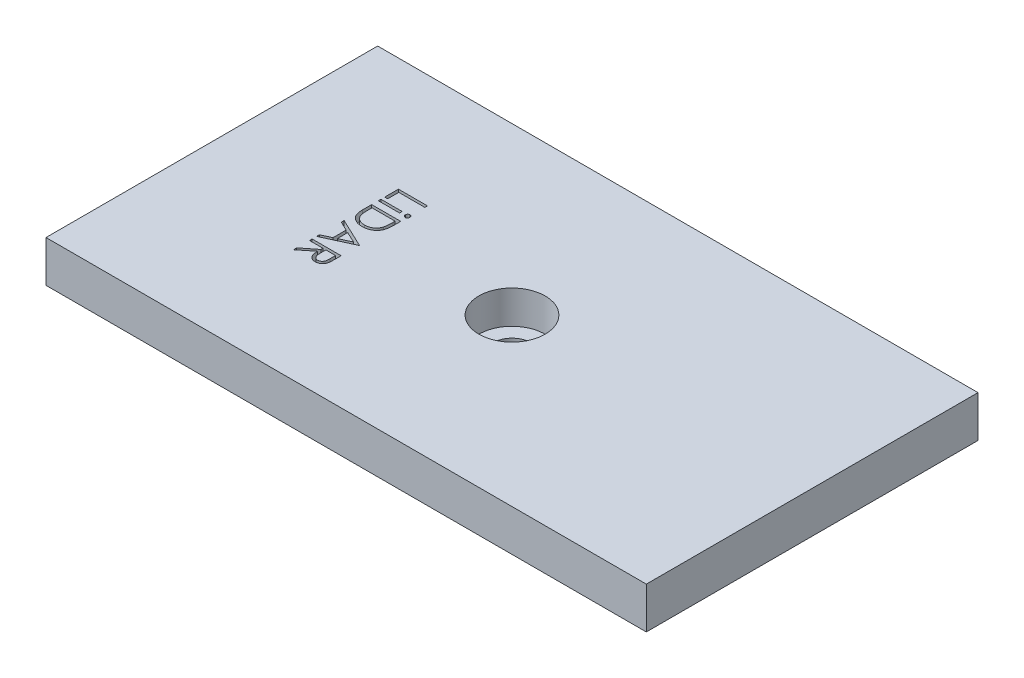
from build123d import *

# Parameters (mm, degrees)
SKETCH1_W                      = 72.4
SKETCH1_H                      = 40
BOSS_EXTRUDE1_DEPTH            = 6
CHAMFER1_SIZE                  = 1
CBORE_FOR_M4_SHCS1_D           = 4.5
CBORE_FOR_M4_SHCS1_DEPTH       = 6
CBORE_FOR_M4_SHCS1_CBORE_D     = 8
CBORE_FOR_M4_SHCS1_CBORE_DEPTH = 4
SKETCH4_W                      = 2.557692308
SKETCH4_H                      = 0.314102565
CUT_EXTRUDE1_DEPTH             = 1


with BuildPart() as part:
    # Sketch1 → Boss-Extrude1 (new body)
    with BuildSketch(Plane(origin=(0, 0, 0), x_dir=(1, 0, 0), z_dir=(0, 1, 0))):
        Rectangle(SKETCH1_W, SKETCH1_H)
    extrude(amount=BOSS_EXTRUDE1_DEPTH)

    # Chamfer1
    chamfer1_edges = [part.edges().sort_by_distance(p)[0] for p in [
        (0, 0, 20),
        (-36.2, 0, 0),
        (0, 0, -20),
        (36.2, 0, 0),
    ]]
    chamfer(chamfer1_edges, length=CHAMFER1_SIZE)

    # CBORE for M4 SHCS1
    with Locations(Plane(origin=(0, 6, 0), x_dir=(1, 0, 0), z_dir=(0, 1, 0))):
        with Locations((0, 0)):
            CounterBoreHole(CBORE_FOR_M4_SHCS1_D / 2, CBORE_FOR_M4_SHCS1_CBORE_D / 2, CBORE_FOR_M4_SHCS1_CBORE_DEPTH, depth=CBORE_FOR_M4_SHCS1_DEPTH)

    # Sketch4 → Cut-Extrude1 (cut)
    with BuildSketch(Plane(origin=(0, 6, 0), x_dir=(1, 0, 0), z_dir=(0, 1, 0))):
        Polygon((-16.5, 6.304487179), (-16.5, 5.990384615), (-19.641025641, 5.990384615), (-19.641025641, 4.644230769), (-20, 4.644230769), (-20, 6.304487179), align=None)
        with BuildLine():
            add(Edge.make_bspline(
                [(-16.365384615, 4.039863782), (-16.36629269, 4.020375721), (-16.368070874, 3.982214354), (-16.383176643, 3.92697486), (-16.409172417, 3.876726064), (-16.442915564, 3.831491473), (-16.484230683, 3.793994076), (-16.53117379, 3.767106447), (-16.58227867, 3.749941466), (-16.617887461, 3.747856453), (-16.636017628, 3.746794872)],
                knots=[0, 0, 0, 0, 5.84e-05, 0.000114358, 0.000170171, 0.000227242, 0.000282848, 0.000336244, 0.00038857, 0.000442847, 0.000442847, 0.000442847, 0.000442847], degree=3))
            add(Edge.make_bspline(
                [(-16.636017628, 3.746794872), (-16.653677192, 3.747880202), (-16.688588061, 3.75002577), (-16.738806847, 3.767093758), (-16.785096281, 3.794219497), (-16.826330626, 3.831466515), (-16.86005428, 3.876732655), (-16.886055203, 3.926973116), (-16.901159612, 3.982214812), (-16.902937984, 4.020375876), (-16.903846154, 4.039863782)],
                knots=[0, 0, 0, 0, 5.2882e-05, 0.000104542, 0.000157332, 0.000212937, 0.000270009, 0.000325822, 0.00038178, 0.00044018, 0.00044018, 0.00044018, 0.00044018], degree=3))
            add(Edge.make_bspline(
                [(-16.903846154, 4.039863782), (-16.902967151, 4.059127865), (-16.901256287, 4.096622886), (-16.885874492, 4.150846688), (-16.860110821, 4.200286964), (-16.825863936, 4.2447818), (-16.785370463, 4.282767293), (-16.738771881, 4.309792946), (-16.688596963, 4.326906568), (-16.653680183, 4.329045986), (-16.636017628, 4.330128205)],
                knots=[0, 0, 0, 0, 5.7701e-05, 0.000112308, 0.000167496, 0.000224009, 0.000280086, 0.000332875, 0.000384535, 0.000437418, 0.000437418, 0.000437418, 0.000437418], degree=3))
            add(Edge.make_bspline(
                [(-16.636017628, 4.330128205), (-16.617884357, 4.32906985), (-16.582269469, 4.326991175), (-16.531209353, 4.309779663), (-16.483954162, 4.282995494), (-16.443381916, 4.244757256), (-16.409116, 4.200293389), (-16.383357305, 4.150845015), (-16.36797421, 4.096623331), (-16.366263526, 4.059128016), (-16.365384615, 4.039863782)],
                knots=[0, 0, 0, 0, 5.4277e-05, 0.000106603, 0.000159999, 0.000216076, 0.000272589, 0.000327778, 0.000382384, 0.000440085, 0.000440085, 0.000440085, 0.000440085], degree=3))
        make_face()
        with Locations((-18.721153846, 4.038461539)):
            Rectangle(SKETCH4_W, SKETCH4_H)
        with BuildLine():
            Line((-20, 3.073717949), (-16.5, 3.073717949))
            Line((-16.5, 3.073717949), (-16.5, 2.366987179))
            add(Edge.make_bspline(
                [(-16.5, 2.366987179), (-16.500441364, 2.305518063), (-16.501294077, 2.186760051), (-16.506731622, 2.015149315), (-16.516253523, 1.856592024), (-16.530390835, 1.711178219), (-16.547359571, 1.578674282), (-16.568939567, 1.459292433), (-16.594319104, 1.352839205), (-16.615965573, 1.287369893), (-16.626201923, 1.256410256)],
                knots=[0, 0, 0, 0, 0.000184407, 0.000356273, 0.000515031, 0.000660839, 0.000794505, 0.000915661, 0.001024663, 0.001122451, 0.001122451, 0.001122451, 0.001122451], degree=3))
            add(Edge.make_bspline(
                [(-16.626201923, 1.256410256), (-16.641632646, 1.215915543), (-16.672144174, 1.135844401), (-16.729700224, 1.021836906), (-16.794914263, 0.914512932), (-16.867866673, 0.813288668), (-16.950643905, 0.720506945), (-17.039652514, 0.632427168), (-17.138529639, 0.553003306), (-17.243918105, 0.479048035), (-17.356887031, 0.414335964), (-17.475143662, 0.357267433), (-17.598466726, 0.308540873), (-17.727753834, 0.270520736), (-17.861763837, 0.239109628), (-18.001511188, 0.218033522), (-18.146181197, 0.204033518), (-18.244356924, 0.202633458), (-18.294170673, 0.201923077)],
                knots=[0, 0, 0, 0, 0.000129935, 0.000256923, 0.000382457, 0.000506429, 0.000630624, 0.000755071, 0.000881654, 0.001010603, 0.001140963, 0.001271727, 0.001404269, 0.001538244, 0.001675666, 0.001816872, 0.001961916, 0.002111314, 0.002111314, 0.002111314, 0.002111314], degree=3))
            add(Edge.make_bspline(
                [(-18.294170673, 0.201923077), (-18.337431765, 0.202552468), (-18.422682266, 0.20379275), (-18.548325256, 0.214915999), (-18.670231175, 0.231114488), (-18.787864626, 0.256078288), (-18.902018041, 0.286752778), (-19.012149321, 0.324614557), (-19.118339189, 0.369484432), (-19.219722654, 0.421542498), (-19.316131997, 0.478465682), (-19.405908182, 0.540878622), (-19.490758634, 0.605199855), (-19.566856155, 0.676388957), (-19.638553014, 0.749540211), (-19.701975299, 0.828532684), (-19.759885634, 0.910792849), (-19.811861317, 0.997905167), (-19.856955979, 1.091957586), (-19.895587774, 1.194233797), (-19.927397179, 1.305281562), (-19.95397895, 1.424930671), (-19.975053061, 1.553415572), (-19.989180388, 1.690854121), (-19.998733053, 1.83703753), (-19.999569484, 1.937416778), (-20, 1.989082532)],
                knots=[0, 0, 0, 0, 0.000129755, 0.000255696, 0.000378151, 0.000498469, 0.000616165, 0.000732571, 0.000847557, 0.000961693, 0.00107424, 0.001183147, 0.00128959, 0.001393302, 0.001495449, 0.001596627, 0.001696799, 0.001797082, 0.001900566, 0.002009296, 0.002124673, 0.002246805, 0.002376823, 0.002515029, 0.002661147, 0.00281612, 0.00281612, 0.00281612, 0.00281612], degree=3))
            Line((-20, 1.989082532), (-20, 3.073717949))
        make_face()
        with BuildLine():
            Line((-19.641025641, 2.759615385), (-19.641025641, 2.357872596))
            add(Edge.make_bspline(
                [(-19.641025641, 2.357872596), (-19.640777545, 2.300144225), (-19.640300364, 2.189111427), (-19.636113161, 2.02945343), (-19.629271224, 1.883574033), (-19.619696146, 1.751452524), (-19.607027531, 1.6331635), (-19.592902628, 1.52845975), (-19.575305177, 1.437684491), (-19.559354218, 1.382755054), (-19.551983173, 1.357371795)],
                knots=[0, 0, 0, 0, 0.000173183, 0.000333094, 0.000479096, 0.000611272, 0.000730431, 0.000835931, 0.000928194, 0.001007458, 0.001007458, 0.001007458, 0.001007458], degree=3))
            add(Edge.make_bspline(
                [(-19.551983173, 1.357371795), (-19.540732453, 1.325422757), (-19.518499737, 1.262287784), (-19.477929951, 1.171416467), (-19.429932617, 1.086623422), (-19.376265429, 1.006494005), (-19.316097236, 0.931547084), (-19.249245929, 0.86211514), (-19.176450828, 0.797704694), (-19.09743924, 0.739020336), (-19.012721991, 0.68658277), (-18.923377605, 0.640877622), (-18.829621713, 0.602097478), (-18.731116394, 0.570563618), (-18.627954501, 0.546126688), (-18.52040743, 0.528740101), (-18.40844163, 0.517931407), (-18.332289855, 0.516669123), (-18.293469551, 0.516025641)],
                knots=[0, 0, 0, 0, 0.000101593, 0.000200759, 0.000298073, 0.000393552, 0.0004898, 0.000585999, 0.000682362, 0.000781081, 0.000880892, 0.000980919, 0.001081827, 0.00118493, 0.001290876, 0.00139957, 0.001511544, 0.001627983, 0.001627983, 0.001627983, 0.001627983], degree=3))
            add(Edge.make_bspline(
                [(-18.293469551, 0.516025641), (-18.252536316, 0.516539475), (-18.172122613, 0.517548908), (-18.054128443, 0.530215463), (-17.940660382, 0.548765119), (-17.831636737, 0.575447354), (-17.72719935, 0.6099185), (-17.626758196, 0.65116602), (-17.531605855, 0.701246984), (-17.440936425, 0.757943931), (-17.356123035, 0.821596637), (-17.278159321, 0.891922741), (-17.206900054, 0.968180698), (-17.142231778, 1.050019059), (-17.08530453, 1.138582062), (-17.034662938, 1.232371046), (-16.99163483, 1.332707155), (-16.968757647, 1.402521165), (-16.95713141, 1.438000801)],
                knots=[0, 0, 0, 0, 0.000122746, 0.000241136, 0.000355593, 0.000467485, 0.000577457, 0.000685268, 0.000792832, 0.000899628, 0.001005778, 0.001110527, 0.001214201, 0.001318555, 0.001422987, 0.00152964, 0.001637997, 0.001749968, 0.001749968, 0.001749968, 0.001749968], degree=3))
            add(Edge.make_bspline(
                [(-16.95713141, 1.438000801), (-16.949014982, 1.467351948), (-16.93175723, 1.529760538), (-16.912931857, 1.631600002), (-16.896327358, 1.746215151), (-16.882269319, 1.874114853), (-16.872181998, 2.015153312), (-16.864610683, 2.169439), (-16.859504051, 2.337038604), (-16.859155343, 2.453221138), (-16.858974359, 2.513521635)],
                knots=[0, 0, 0, 0, 9.1321e-05, 0.000194173, 0.000310382, 0.000438754, 0.000580072, 0.000734511, 0.000902151, 0.001083046, 0.001083046, 0.001083046, 0.001083046], degree=3))
            Line((-16.858974359, 2.513521635), (-16.858974359, 2.759615385))
            Line((-16.858974359, 2.759615385), (-19.641025641, 2.759615385))
        make_face(mode=Mode.SUBTRACT)
        Polygon((-16.5, -1.951923077), (-20, -3.567307692), (-20, -3.225861378), (-18.878205128, -2.708433494), (-18.878205128, -1.121794872), (-20, -0.590344551), (-20, -0.246794872), (-16.5, -1.907051282), align=None)
        Polygon((-17.182892628, -1.925981571), (-18.519230769, -1.29286859), (-18.519230769, -2.54296875), align=None, mode=Mode.SUBTRACT)
        with BuildLine():
            Line((-16.5, -4.105769231), (-16.5, -4.806189904))
            add(Edge.make_bspline(
                [(-16.5, -4.806189904), (-16.500155586, -4.852931032), (-16.500454328, -4.942679177), (-16.502120091, -5.071252447), (-16.506894447, -5.188079544), (-16.51100303, -5.293099383), (-16.518494972, -5.386310038), (-16.525655619, -5.467997329), (-16.53502928, -5.537785027), (-16.543734703, -5.580030878), (-16.547676282, -5.599158654)],
                knots=[0, 0, 0, 0, 0.000140226, 0.00026925, 0.000385712, 0.000490995, 0.000584507, 0.000666202, 0.000736998, 0.000795574, 0.000795574, 0.000795574, 0.000795574], degree=3))
            add(Edge.make_bspline(
                [(-16.547676282, -5.599158654), (-16.55400233, -5.624765729), (-16.566519473, -5.675433611), (-16.592989487, -5.748377133), (-16.623570695, -5.817915599), (-16.659768254, -5.88378805), (-16.700950797, -5.946000596), (-16.747358942, -6.00446009), (-16.799229026, -6.058832302), (-16.855236506, -6.109535598), (-16.915870063, -6.155496505), (-16.980246433, -6.195269656), (-17.047962977, -6.229327206), (-17.11925551, -6.256516372), (-17.19352137, -6.278389222), (-17.27140904, -6.293816874), (-17.352570327, -6.303067671), (-17.407928192, -6.304009581), (-17.435997596, -6.304487179)],
                knots=[0, 0, 0, 0, 7.9081e-05, 0.000156475, 0.000232432, 0.000306798, 0.000381663, 0.000456012, 0.000530404, 0.000606855, 0.000682436, 0.000758316, 0.000833569, 0.000909478, 0.00098691, 0.001065561, 0.0011474, 0.001231581, 0.001231581, 0.001231581, 0.001231581], degree=3))
            add(Edge.make_bspline(
                [(-17.435997596, -6.304487179), (-17.482632754, -6.30301822), (-17.573630027, -6.300151898), (-17.705690159, -6.273426262), (-17.828882215, -6.22965169), (-17.943034754, -6.169321226), (-18.045982774, -6.092528302), (-18.136099546, -6.00024067), (-18.212207266, -5.892929636), (-18.264423869, -5.792561082), (-18.29802227, -5.703858698), (-18.321780902, -5.630619028), (-18.339827879, -5.550666264), (-18.356230059, -5.465147449), (-18.368746241, -5.373402029), (-18.377635108, -5.275614755), (-18.383350718, -5.171541056), (-18.384185793, -5.100201295), (-18.384615385, -5.063501603)],
                knots=[0, 0, 0, 0, 0.000139777, 0.000272741, 0.000402249, 0.000530843, 0.000658588, 0.000786009, 0.00091617, 0.001051951, 0.001124085, 0.001200584, 0.001282723, 0.001369767, 0.001461782, 0.001560362, 0.001664279, 0.001774375, 0.001774375, 0.001774375, 0.001774375], degree=3))
            Line((-18.384615385, -5.063501603), (-20, -6.349358974))
            Line((-20, -6.349358974), (-20, -5.9609375))
            Line((-20, -5.9609375), (-18.384615385, -4.675080128))
            Line((-18.384615385, -4.675080128), (-18.384615385, -4.419871795))
            Line((-18.384615385, -4.419871795), (-20, -4.419871795))
            Line((-20, -4.419871795), (-20, -4.105769231))
            Line((-20, -4.105769231), (-16.5, -4.105769231))
        make_face()
        with BuildLine():
            Line((-16.858974359, -4.419871795), (-18.025641026, -4.419871795))
            Line((-18.025641026, -4.419871795), (-18.030548878, -5.060697115))
            add(Edge.make_bspline(
                [(-18.030548878, -5.060697115), (-18.030562115, -5.090617154), (-18.030587771, -5.148610711), (-18.026593996, -5.232511378), (-18.022050673, -5.310631484), (-18.015101343, -5.382672255), (-18.006145223, -5.448665767), (-17.994942396, -5.508579385), (-17.98188982, -5.56250977), (-17.961690357, -5.625411121), (-17.929669718, -5.695628637), (-17.883161564, -5.77203468), (-17.824285939, -5.836879853), (-17.758032574, -5.892788961), (-17.683690187, -5.935853213), (-17.604558557, -5.967196434), (-17.521320853, -5.986866051), (-17.46414901, -5.989204491), (-17.435296474, -5.990384615)],
                knots=[0, 0, 0, 0, 8.9746e-05, 0.000173954, 0.000251933, 0.000324488, 0.000391021, 0.000451663, 0.000507268, 0.000557378, 0.000649639, 0.000738152, 0.000824558, 0.000911186, 0.000997284, 0.001081, 0.00116587, 0.001252339, 0.001252339, 0.001252339, 0.001252339], degree=3))
            add(Edge.make_bspline(
                [(-17.435296474, -5.990384615), (-17.407142095, -5.989200863), (-17.351350389, -5.986855098), (-17.269896953, -5.967158323), (-17.192470091, -5.935350912), (-17.120545612, -5.89074956), (-17.05471362, -5.836855667), (-16.999164703, -5.772848655), (-16.952645723, -5.701951996), (-16.923135579, -5.635641774), (-16.905007029, -5.576413617), (-16.892265865, -5.524981511), (-16.881943017, -5.466646741), (-16.873917197, -5.401549109), (-16.866694876, -5.329806388), (-16.862012115, -5.251222133), (-16.859181853, -5.16588709), (-16.859045133, -5.106739908), (-16.858974359, -5.076121795)],
                knots=[0, 0, 0, 0, 8.4371e-05, 0.000167192, 0.000249871, 0.000334524, 0.000420164, 0.000504127, 0.000587748, 0.000673744, 0.000720756, 0.00077347, 0.000832606, 0.000898351, 0.000970208, 0.001048887, 0.00113447, 0.00122632, 0.00122632, 0.00122632, 0.00122632], degree=3))
            Line((-16.858974359, -5.076121795), (-16.858974359, -4.419871795))
        make_face(mode=Mode.SUBTRACT)
    extrude(amount=-CUT_EXTRUDE1_DEPTH, mode=Mode.SUBTRACT)


solid = part.part
